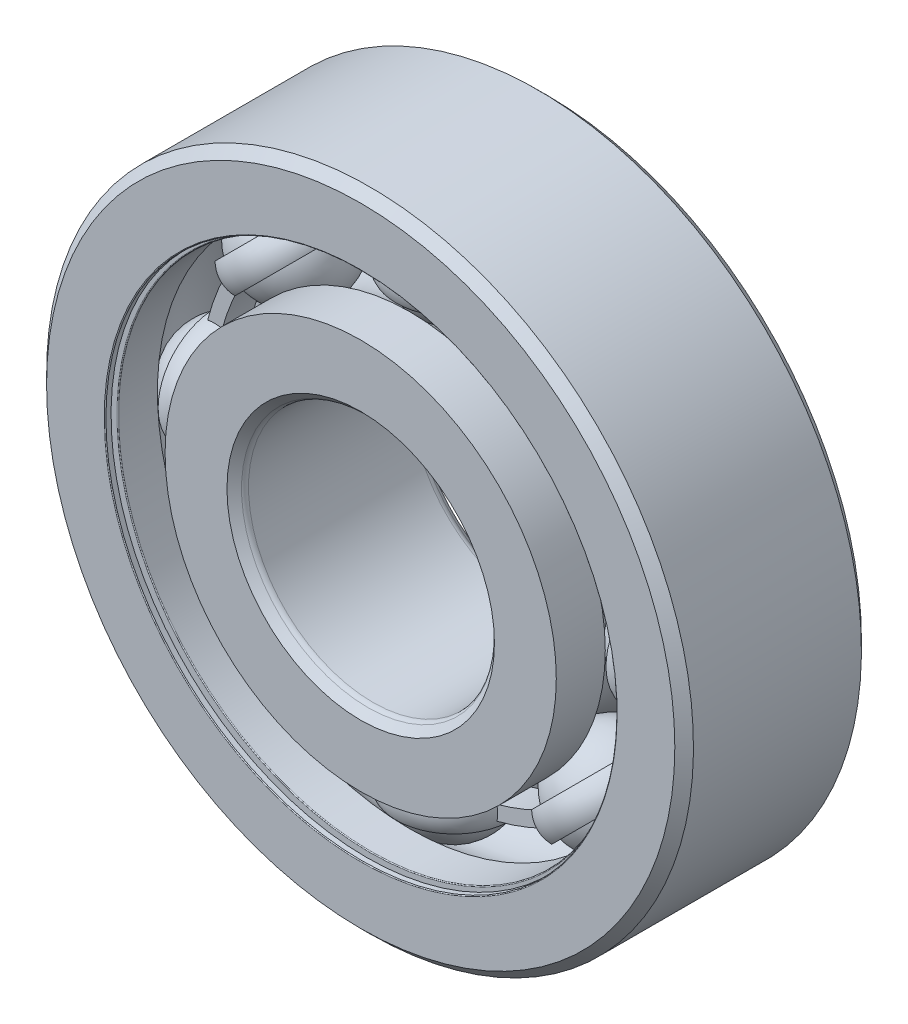
from build123d import *

# Parameters (mm, degrees)
BOSS_EXTRUDE1_DEPTH = 1.25
CIRPATTERN1_COUNT   = 8
CIRPATTERN2_COUNT   = 8
FILLET1_R           = 0.0675
FILLET2_R           = 0.5625


with BuildPart() as part:
    # Sketch3 → Revolve1 (revolve)
    with BuildSketch(Plane(origin=(0, 0, 0), x_dir=(0, 0, -1), z_dir=(1, 0, 0))):
        with BuildLine():
            Line((6.75, 26), (7.5, 25.25))
            Line((7.5, 25.25), (7.5, 20.276923077))
            Line((7.5, 20.276923077), (3.5625, 20.276923077))
            ThreePointArc((3.5625, 20.276923077), (0, 22.22797646), (-3.5625, 20.276923077))
            Line((-3.5625, 20.276923077), (-7.5, 20.276923077))
            Line((-7.5, 20.276923077), (-7.5, 25.25))
            Line((-7.5, 25.25), (-6.75, 26))
            Line((-6.75, 26), (6.75, 26))
        make_face()
    revolve(axis=Axis((0, 0, 7.5), (0, 0, -1)))

    # Sketch8 → Cut-Revolve1 (revolve, cut)
    with BuildSketch(Plane(origin=(0, 0, 0), x_dir=(0, 0, -1), z_dir=(1, 0, 0))):
        Polygon((-7.02, 20.276923077), (-6.75, 20.276923077), (-6.75, 22.184615385), (-7.02, 22.184615385), (-7.02, 20.546923077), (-7.5, 20.546923077), (-7.5, 20.276923077), align=None)
        Polygon((6.75, 20.276923077), (7.02, 20.276923077), (7.5, 20.276923077), (7.5, 20.546923077), (7.02, 20.546923077), (7.02, 22.184615385), (6.75, 22.184615385), align=None)
    revolve(axis=Axis((0, 0, 7.5), (0, 0, -1)), mode=Mode.SUBTRACT)

    # Fillet1
    fillet1_edges = [part.edges().sort_by_distance(p)[0] for p in [
        (0, -20.276923077, -6.75),
        (0, -20.546923077, -7.5),
        (0, -20.276923077, 6.75),
        (0, -20.546923077, 7.5),
    ]]
    fillet(fillet1_edges, radius=FILLET1_R)


with BuildPart() as body_2:
    # Sketch4 → Revolve2 (revolve)
    with BuildSketch(Plane(origin=(0, 0, 0), x_dir=(0, 0, -1), z_dir=(1, 0, 0))):
        with BuildLine():
            Line((-6.75, 10), (-7.5, 10.75))
            Line((-7.5, 10.75), (-7.5, 15.723076923))
            Line((-7.5, 15.723076923), (-3.5625, 15.723076923))
            ThreePointArc((-3.5625, 15.723076923), (0, 13.77202354), (3.5625, 15.723076923))
            Line((3.5625, 15.723076923), (7.5, 15.723076923))
            Line((7.5, 15.723076923), (7.5, 10.75))
            Line((7.5, 10.75), (6.75, 10))
            Line((6.75, 10), (-6.75, 10))
        make_face()
    revolve(axis=Axis((0, 0, 7.5), (0, 0, -1)))

    # Fillet2
    fillet2_edges = [body_2.edges().sort_by_distance(p)[0] for p in [
        (0, -10, -6.75),
        (0, -10, 6.75),
    ]]
    fillet(fillet2_edges, radius=FILLET2_R)


with BuildPart() as body_3:
    # Sketch5 → Revolve3 (revolve)
    with BuildSketch(Plane(origin=(0, 0, 0), x_dir=(0, 0, -1), z_dir=(1, 0, 0))):
        with BuildLine():
            Line((-4.22797646, 18), (4.22797646, 18))
            ThreePointArc((4.22797646, 18), (0, 22.22797646), (-4.22797646, 18))
        make_face()
    revolve(axis=Axis((0, 18, 4.22797646), (0, 0, -1)))


with BuildPart() as body_4:
    # Sketch6 → Revolve4 (revolve)
    with BuildSketch(Plane(origin=(0, 0, 0), x_dir=(0, 0, -1), z_dir=(1, 0, 0))):
        with BuildLine():
            Line((-4.071816582, 19.138461538), (-4.643180485, 19.138461538))
            ThreePointArc((-4.643180485, 19.138461538), (-4.928862436, 18), (-4.643180485, 16.861538462))
            Line((-4.643180485, 16.861538462), (-4.071816582, 16.861538462))
            ThreePointArc((-4.071816582, 16.861538462), (-4.22797646, 18), (-4.071816582, 19.138461538))
        make_face()
    revolve4 = revolve(axis=Axis((0, 26, 0), (0, -1, 0)))

    # Sketch7 → Boss-Extrude1 (add, symmetric)
    with BuildSketch(Plane.XY):
        with BuildLine():
            Line((13.075238968, 12.37085793), (13.902219895, 13.15328826))
            ThreePointArc((13.902219895, 13.15328826), (7.567926023, 17.578600791), (0, 19.138461538))
            Line((0, 19.138461538), (0, 18))
            ThreePointArc((0, 18), (7.117743928, 16.532928397), (13.075238968, 12.37085793))
        make_face()
    boss_extrude1 = extrude(amount=BOSS_EXTRUDE1_DEPTH, both=True)

    # CirPattern2: Revolve4, Boss-Extrude1 ×8 about axis
    cirpattern2_axis = Axis((0, 0, 7.5), (0, 0, -1))
    add([revolve4.rotate(cirpattern2_axis, i * 360 / CIRPATTERN2_COUNT) for i in range(1, CIRPATTERN2_COUNT)])
    add([boss_extrude1.rotate(cirpattern2_axis, i * 360 / CIRPATTERN2_COUNT) for i in range(1, CIRPATTERN2_COUNT)])


with BuildPart() as cirpattern1_1:
    # CirPattern1: pattern copy
    add(body_3.part.rotate(Axis((0, 0, 7.5), (0, 0, -1)), 1 * 360 / CIRPATTERN1_COUNT))


with BuildPart() as cirpattern1_2:
    # CirPattern1: pattern copy
    add(body_3.part.rotate(Axis((0, 0, 7.5), (0, 0, -1)), 2 * 360 / CIRPATTERN1_COUNT))


with BuildPart() as cirpattern1_3:
    # CirPattern1: pattern copy
    add(body_3.part.rotate(Axis((0, 0, 7.5), (0, 0, -1)), 3 * 360 / CIRPATTERN1_COUNT))


with BuildPart() as cirpattern1_4:
    # CirPattern1: pattern copy
    add(body_3.part.rotate(Axis((0, 0, 7.5), (0, 0, -1)), 4 * 360 / CIRPATTERN1_COUNT))


with BuildPart() as cirpattern1_5:
    # CirPattern1: pattern copy
    add(body_3.part.rotate(Axis((0, 0, 7.5), (0, 0, -1)), 5 * 360 / CIRPATTERN1_COUNT))


with BuildPart() as cirpattern1_6:
    # CirPattern1: pattern copy
    add(body_3.part.rotate(Axis((0, 0, 7.5), (0, 0, -1)), 6 * 360 / CIRPATTERN1_COUNT))


with BuildPart() as cirpattern1_7:
    # CirPattern1: pattern copy
    add(body_3.part.rotate(Axis((0, 0, 7.5), (0, 0, -1)), 7 * 360 / CIRPATTERN1_COUNT))


solid = Compound([part.part, body_2.part, body_3.part, body_4.part, cirpattern1_1.part, cirpattern1_2.part, cirpattern1_3.part, cirpattern1_4.part, cirpattern1_5.part, cirpattern1_6.part, cirpattern1_7.part])
